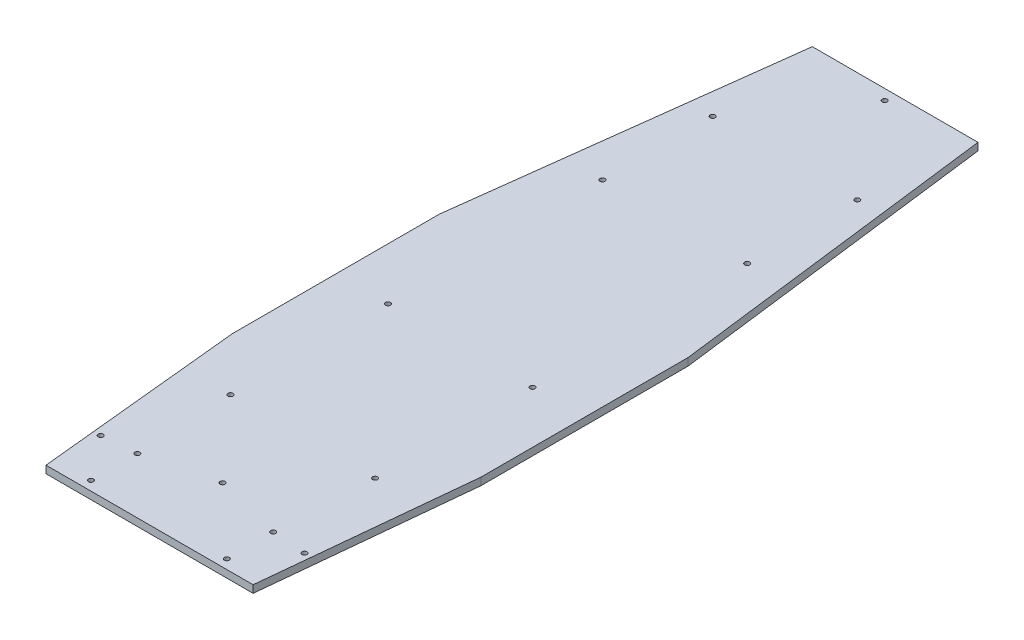
from build123d import *

# Parameters (mm, degrees)
BOSS_EXTRUDE1_DEPTH                = 9
F_6_0_6_DIAMETER_HOLE1_AT_2_COUNT  = 2
F_6_0_6_DIAMETER_HOLE1_AT_2_PITCH  = 148.638420336
F_6_0_6_DIAMETER_HOLE1_AT_3_COUNT  = 2
F_6_0_6_DIAMETER_HOLE1_AT_3_PITCH  = 267.921966251
F_6_0_6_DIAMETER_HOLE1_AT_4_COUNT  = 2
F_6_0_6_DIAMETER_HOLE1_AT_4_PITCH  = 267.921966251
F_6_0_6_DIAMETER_HOLE1_AT_5_COUNT  = 2
F_6_0_6_DIAMETER_HOLE1_AT_5_PITCH  = 148.638420336
F_6_0_6_DIAMETER_HOLE1_AT_6_COUNT  = 2
F_6_0_6_DIAMETER_HOLE1_AT_6_PITCH  = 519.685077715
F_6_0_6_DIAMETER_HOLE1_AT_7_COUNT  = 2
F_6_0_6_DIAMETER_HOLE1_AT_7_PITCH  = 519.685077715
F_6_0_6_DIAMETER_HOLE1_AT_8_COUNT  = 2
F_6_0_6_DIAMETER_HOLE1_AT_8_PITCH  = 707.705150469
F_6_0_6_DIAMETER_HOLE1_AT_9_COUNT  = 2
F_6_0_6_DIAMETER_HOLE1_AT_9_PITCH  = 707.705150469
F_6_0_6_DIAMETER_HOLE1_AT_10_COUNT = 2
F_6_0_6_DIAMETER_HOLE1_AT_10_PITCH = 799.1
F_6_0_6_DIAMETER_HOLE3_D           = 6
F_6_0_6_DIAMETER_HOLE3_DEPTH       = 34.5
F_6_0_6_DIAMETER_HOLE3_TIP         = 1.802581857
F_6_0_6_DIAMETER_HOLE4_AT_2_COUNT  = 2
F_6_0_6_DIAMETER_HOLE4_AT_2_PITCH  = 246
F_6_0_6_DIAMETER_HOLE5_AT_2_COUNT  = 2
F_6_0_6_DIAMETER_HOLE5_AT_2_PITCH  = 56
F_6_0_6_DIAMETER_HOLE5_AT_3_COUNT  = 2
F_6_0_6_DIAMETER_HOLE5_AT_3_PITCH  = 164
F_6_0_6_DIAMETER_HOLE5_AT_4_COUNT  = 2
F_6_0_6_DIAMETER_HOLE5_AT_4_PITCH  = 173.297432179


with BuildPart() as part:
    # Sketch1 → Boss-Extrude1 (new body)
    with BuildSketch(Plane(origin=(0, 0, 0), x_dir=(1, 0, 0), z_dir=(0, 1, 0))):
        Polygon((-150, -125), (-150, 125), (-100, 525), (100, 525), (150, 125), (150, -125), (125, -375), (-125, -375), align=None)
    extrude(amount=BOSS_EXTRUDE1_DEPTH)

    # Sketch5 → Ø6.0 (6) Diameter Hole1 (revolve, cut)
    with BuildSketch(Plane(origin=(0, 9, -512.3), x_dir=(0, 0, 1), z_dir=(1, 0, 0))):
        Polygon((0, 0), (0, 9), (6, 9), (3, 6), (3, 0), align=None)
    f_6_0_6_diameter_hole1 = revolve(axis=Axis((0, 15.35, -512.3), (0, -1, 0)), mode=Mode.SUBTRACT)

    # Ø6.0 (6) Diameter Hole1 at 2: Ø6.0 (6) Diameter Hole1 ×2
    with Locations(*[Vector(-0.587331323, 0, 0.809346599) * (i * F_6_0_6_DIAMETER_HOLE1_AT_2_PITCH) for i in range(1, F_6_0_6_DIAMETER_HOLE1_AT_2_COUNT)]):
        add(f_6_0_6_diameter_hole1, mode=Mode.SUBTRACT)

    # Ø6.0 (6) Diameter Hole1 at 3: Ø6.0 (6) Diameter Hole1 ×2
    with Locations(*[Vector(-0.325841144, 0, 0.945424534) * (i * F_6_0_6_DIAMETER_HOLE1_AT_3_PITCH) for i in range(1, F_6_0_6_DIAMETER_HOLE1_AT_3_COUNT)]):
        add(f_6_0_6_diameter_hole1, mode=Mode.SUBTRACT)

    # Ø6.0 (6) Diameter Hole1 at 4: Ø6.0 (6) Diameter Hole1 ×2
    with Locations(*[Vector(0.325841144, 0, 0.945424534) * (i * F_6_0_6_DIAMETER_HOLE1_AT_4_PITCH) for i in range(1, F_6_0_6_DIAMETER_HOLE1_AT_4_COUNT)]):
        add(f_6_0_6_diameter_hole1, mode=Mode.SUBTRACT)

    # Ø6.0 (6) Diameter Hole1 at 5: Ø6.0 (6) Diameter Hole1 ×2
    with Locations(*[Vector(0.587331323, 0, 0.809346599) * (i * F_6_0_6_DIAMETER_HOLE1_AT_5_PITCH) for i in range(1, F_6_0_6_DIAMETER_HOLE1_AT_5_COUNT)]):
        add(f_6_0_6_diameter_hole1, mode=Mode.SUBTRACT)

    # Ø6.0 (6) Diameter Hole1 at 6: Ø6.0 (6) Diameter Hole1 ×2
    with Locations(*[Vector(0.167986351, 0, 0.985789321) * (i * F_6_0_6_DIAMETER_HOLE1_AT_6_PITCH) for i in range(1, F_6_0_6_DIAMETER_HOLE1_AT_6_COUNT)]):
        add(f_6_0_6_diameter_hole1, mode=Mode.SUBTRACT)

    # Ø6.0 (6) Diameter Hole1 at 7: Ø6.0 (6) Diameter Hole1 ×2
    with Locations(*[Vector(-0.167986351, 0, 0.985789321) * (i * F_6_0_6_DIAMETER_HOLE1_AT_7_PITCH) for i in range(1, F_6_0_6_DIAMETER_HOLE1_AT_7_COUNT)]):
        add(f_6_0_6_diameter_hole1, mode=Mode.SUBTRACT)

    # Ø6.0 (6) Diameter Hole1 at 8: Ø6.0 (6) Diameter Hole1 ×2
    with Locations(*[Vector(-0.123356457, 0, 0.992362426) * (i * F_6_0_6_DIAMETER_HOLE1_AT_8_PITCH) for i in range(1, F_6_0_6_DIAMETER_HOLE1_AT_8_COUNT)]):
        add(f_6_0_6_diameter_hole1, mode=Mode.SUBTRACT)

    # Ø6.0 (6) Diameter Hole1 at 9: Ø6.0 (6) Diameter Hole1 ×2
    with Locations(*[Vector(0.123356457, 0, 0.992362426) * (i * F_6_0_6_DIAMETER_HOLE1_AT_9_PITCH) for i in range(1, F_6_0_6_DIAMETER_HOLE1_AT_9_COUNT)]):
        add(f_6_0_6_diameter_hole1, mode=Mode.SUBTRACT)

    # Ø6.0 (6) Diameter Hole1 at 10: Ø6.0 (6) Diameter Hole1 ×2
    with Locations(*[(0, 0, i * F_6_0_6_DIAMETER_HOLE1_AT_10_PITCH) for i in range(1, F_6_0_6_DIAMETER_HOLE1_AT_10_COUNT)]):
        add(f_6_0_6_diameter_hole1, mode=Mode.SUBTRACT)

    # Ø6.0 (6) Diameter Hole3
    with Locations(Plane(origin=(0, 0, -512.3), x_dir=(0, 0, -1), z_dir=(0, -1, 0))):
        with Locations((0, 0), (-120.3, 87.3), (-120.3, -87.3), (-253.3, -87.3), (-253.3, 87.3), (-512.3, 87.3), (-512.3, -87.3), (-702.3, -87.3), (-702.3, 87.3), (-799.1, 0)):
            Hole(F_6_0_6_DIAMETER_HOLE3_D / 2, depth=F_6_0_6_DIAMETER_HOLE3_DEPTH)
            with Locations((0, 0, -(F_6_0_6_DIAMETER_HOLE3_DEPTH + F_6_0_6_DIAMETER_HOLE3_TIP / 2))):  # 118° drill point
                Cone(0, F_6_0_6_DIAMETER_HOLE3_D / 2, F_6_0_6_DIAMETER_HOLE3_TIP, mode=Mode.SUBTRACT)

    # Sketch10 → Ø6.0 (6) Diameter Hole4 (revolve, cut)
    with BuildSketch(Plane(origin=(123, 9, 311), x_dir=(0, 0, 1), z_dir=(1, 0, 0))):
        Polygon((0, 0), (0, 9), (6, 9), (3, 6), (3, 0), align=None)
    f_6_0_6_diameter_hole4 = revolve(axis=Axis((123, 15.35, 311), (0, -1, 0)), mode=Mode.SUBTRACT)

    # Ø6.0 (6) Diameter Hole4 at 2: Ø6.0 (6) Diameter Hole4 ×2
    with Locations(*[(-i * F_6_0_6_DIAMETER_HOLE4_AT_2_PITCH, 0, 0) for i in range(1, F_6_0_6_DIAMETER_HOLE4_AT_2_COUNT)]):
        add(f_6_0_6_diameter_hole4, mode=Mode.SUBTRACT)

    # Sketch12 → Ø6.0 (6) Diameter Hole5 (revolve, cut)
    with BuildSketch(Plane(origin=(-82, 9, 363.75), x_dir=(0, 0, 1), z_dir=(1, 0, 0))):
        Polygon((0, 0), (0, 9), (6, 9), (3, 6), (3, 0), align=None)
    f_6_0_6_diameter_hole5 = revolve(axis=Axis((-82, 15.35, 363.75), (0, -1, 0)), mode=Mode.SUBTRACT)

    # Ø6.0 (6) Diameter Hole5 at 2: Ø6.0 (6) Diameter Hole5 ×2
    with Locations(*[(0, 0, -i * F_6_0_6_DIAMETER_HOLE5_AT_2_PITCH) for i in range(1, F_6_0_6_DIAMETER_HOLE5_AT_2_COUNT)]):
        add(f_6_0_6_diameter_hole5, mode=Mode.SUBTRACT)

    # Ø6.0 (6) Diameter Hole5 at 3: Ø6.0 (6) Diameter Hole5 ×2
    with Locations(*[(i * F_6_0_6_DIAMETER_HOLE5_AT_3_PITCH, 0, 0) for i in range(1, F_6_0_6_DIAMETER_HOLE5_AT_3_COUNT)]):
        add(f_6_0_6_diameter_hole5, mode=Mode.SUBTRACT)

    # Ø6.0 (6) Diameter Hole5 at 4: Ø6.0 (6) Diameter Hole5 ×2
    with Locations(*[Vector(0.946349856, 0, -0.323143853) * (i * F_6_0_6_DIAMETER_HOLE5_AT_4_PITCH) for i in range(1, F_6_0_6_DIAMETER_HOLE5_AT_4_COUNT)]):
        add(f_6_0_6_diameter_hole5, mode=Mode.SUBTRACT)


solid = part.part
